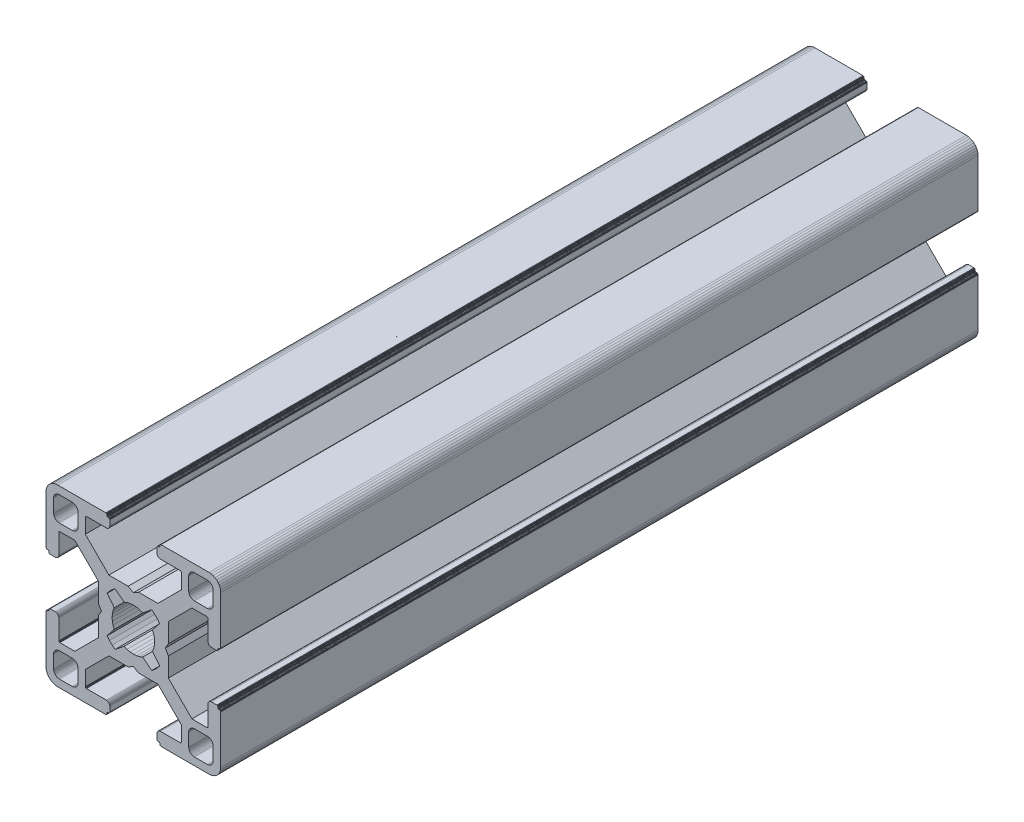
from build123d import *

# Parameters (mm, degrees)
BOSS_EXTRUDE1_DEPTH = 130


with BuildPart() as part:
    # Sketch1 → Boss-Extrude1 (new body)
    with BuildSketch(Plane.XY):
        Polygon((28.34729664, 29.969613999), (28.000000864, 29.999999329), (19.750000909, 29.999999329), (19.715268165, 29.996961355), (19.681595266, 29.987938702), (19.649999216, 29.973205179), (19.621443003, 29.953207821), (19.596790895, 29.928557575), (19.576793537, 29.899999499), (19.562061876, 29.868405312), (19.55303736, 29.834728688), (19.549999386, 29.799999669), (19.549999386, 29.699999839), (19.546961412, 29.665268958), (19.537936896, 29.631596059), (19.523203373, 29.599998146), (19.503207877, 29.571441934), (19.478557631, 29.546789825), (19.449999556, 29.526794329), (19.418403506, 29.512060806), (19.384728745, 29.503038153), (19.349999726, 29.500000179), (19.249999896, 29.500000179), (19.215267517, 29.496958527), (19.181592755, 29.487935874), (19.149996706, 29.47320235), (19.12143863, 29.453206855), (19.096788384, 29.428554746), (19.076791026, 29.399996671), (19.062057503, 29.368402484), (19.05303485, 29.334725859), (19.049996876, 29.299998703), (19.049996876, 28.39999837), (19.059110798, 28.29580945), (19.08618062, 28.194785165), (19.13038119, 28.099997016), (19.190369539, 28.014324653), (19.264324002, 27.94037019), (19.349996366, 27.88038184), (19.444784515, 27.836181271), (19.545806937, 27.809111449), (19.650010894, 27.799984574), (23.050010706, 27.799984574), (23.084741588, 27.7969466), (23.118414487, 27.787923946), (23.150012399, 27.773190423), (23.178568612, 27.753193065), (23.203220721, 27.728542819), (23.223218079, 27.699984744), (23.237949739, 27.668386831), (23.246974255, 27.634713932), (23.25001142, 27.59998608), (23.25001142, 25.049987618), (19.204474482, 20.999982084), (15.900007876, 20.999982084), (15.000008474, 20.48483404), (14.10000814, 20.999982084), (10.795543398, 20.999982084), (7.997342887, 23.801274731), (6.750011387, 25.049984589), (6.750011387, 27.599983051), (6.753049362, 27.634713932), (6.762072946, 27.668386831), (6.776805538, 27.699984744), (6.796801965, 27.728542819), (6.821454073, 27.753193065), (6.850011218, 27.773190423), (6.881607267, 27.787923946), (6.915282029, 27.7969466), (6.950011048, 27.799984574), (10.350011791, 27.799984574), (10.45420071, 27.809098497), (10.555223133, 27.836168318), (10.650011282, 27.880368888), (10.735683645, 27.940357238), (10.809638108, 28.014311701), (10.869626458, 28.099984064), (10.913827027, 28.194772213), (10.940895918, 28.295796498), (10.950010772, 28.399985417), (10.950010772, 29.299985751), (10.946974575, 29.334739239), (10.93795065, 29.368415522), (10.923215933, 29.400009153), (10.903218427, 29.428566473), (10.878566319, 29.45321765), (10.849999264, 29.473204166), (10.818403214, 29.487937689), (10.784728453, 29.496960342), (10.749999434, 29.500000179), (10.649999604, 29.500000179), (10.615270585, 29.503038153), (10.581595823, 29.512060806), (10.549999774, 29.526794329), (10.521441698, 29.546789825), (10.496791452, 29.571441934), (10.476795025, 29.599998146), (10.462061502, 29.631596059), (10.453037918, 29.665268958), (10.449999943, 29.699999839), (10.449999943, 29.799999669), (10.446961969, 29.834728688), (10.437938385, 29.868405312), (10.423205793, 29.899999499), (10.403208435, 29.928557575), (10.378557257, 29.953207821), (10.350000113, 29.973205179), (10.318404064, 29.987938702), (10.284729302, 29.996961355), (10.250000283, 29.999999329), (1.999999397, 29.999999329), (1.652702689, 29.969613999), (1.315958682, 29.879383743), (0.999999233, 29.732050374), (0.714424066, 29.532089829), (0.467910431, 29.285576195), (0.267948955, 28.999999166), (0.120614655, 28.684040532), (0.030384399, 28.34729664), (0, 28.000000864), (0, 19.750000909), (0.003037974, 19.715268165), (0.012061559, 19.681595266), (0.026795082, 19.649999216), (0.046790577, 19.621441141), (0.071442686, 19.596789032), (0.09999983, 19.576793537), (0.13159588, 19.562060013), (0.165270641, 19.55303736), (0.19999966, 19.549999386), (0.299999461, 19.549999386), (0.334728509, 19.546959549), (0.368403242, 19.537936896), (0.399999321, 19.523203373), (0.428556465, 19.503207877), (0.453208573, 19.478555769), (0.473204069, 19.449997693), (0.487937592, 19.418403506), (0.496961176, 19.384728745), (0.499999151, 19.349999726), (0.499999151, 19.249998033), (0.503038056, 19.215269014), (0.512060709, 19.181594253), (0.526794232, 19.150000066), (0.546790194, 19.121441524), (0.571441837, 19.096789882), (0.60000029, 19.076794925), (0.631595686, 19.062061999), (0.665270619, 19.053039982), (0.700000626, 19.050000801), (1.60000096, 19.050000801), (1.704189879, 19.059116587), (1.805213233, 19.086186409), (1.90000045, 19.130385115), (1.985673745, 19.190375328), (2.059627277, 19.264327928), (2.119616325, 19.350002154), (2.163816196, 19.444788441), (2.190886018, 19.545812726), (2.200000872, 19.650001645), (2.200000872, 23.050001457), (2.203039777, 23.084732338), (2.212062431, 23.118405237), (2.226795954, 23.15000315), (2.246792381, 23.178559362), (2.271443558, 23.203211471), (2.300000702, 23.223206967), (2.331596752, 23.23794049), (2.365271513, 23.246965006), (2.400001464, 23.250001117), (4.950000857, 23.250001117), (7.997332093, 20.202670812), (8.995535423, 19.204467788), (8.995535423, 15.900001182), (9.515148227, 15.00000178), (8.995535423, 14.100002378), (8.995535423, 10.795536704), (4.950000857, 6.750002138), (2.400001464, 6.750002138), (2.365271513, 6.753040112), (2.331596752, 6.762063697), (2.300000702, 6.77679722), (2.271443558, 6.796793647), (2.246792381, 6.821444824), (2.226795954, 6.850001968), (2.212062431, 6.881598018), (2.203039777, 6.915272779), (2.200000872, 6.950002729), (2.200000872, 10.350002542), (2.190896812, 10.454174265), (2.16382699, 10.555197618), (2.119627119, 10.649984836), (2.059638071, 10.735658131), (1.985684539, 10.809611663), (1.900011244, 10.869600944), (1.805224027, 10.913800582), (1.704200673, 10.940870404), (1.600011754, 10.949986189), (0.70001142, 10.949986189), (0.665281355, 10.946948596), (0.631606253, 10.937926283), (0.600010578, 10.923193954), (0.571451747, 10.903199537), (0.546799638, 10.87854836), (0.526794232, 10.850000195), (0.512060709, 10.818404146), (0.503038056, 10.784730315), (0.499999151, 10.750000365), (0.499999151, 10.650000535), (0.496961176, 10.615270585), (0.487937592, 10.581596754), (0.473204069, 10.550000705), (0.453208573, 10.521443561), (0.428556465, 10.496791452), (0.399999321, 10.476795956), (0.368403242, 10.462062433), (0.334728509, 10.453038849), (0.299999461, 10.449999943), (0.19999966, 10.449999943), (0.165270641, 10.446961969), (0.13159588, 10.437939316), (0.09999983, 10.423205793), (0.071442686, 10.403209366), (0.046790577, 10.378558189), (0.026795082, 10.350000113), (0.012061559, 10.318404064), (0.003037974, 10.284729302), (0, 10.250000283), (0, 1.999999397), (0.030384399, 1.652702689), (0.120614655, 1.315958682), (0.267948955, 0.999999233), (0.467910431, 0.714424066), (0.714424066, 0.467910431), (0.999999233, 0.267948955), (1.315958682, 0.120614655), (1.652702689, 0.030384399), (1.999999397, 0), (10.250000283, 0), (10.284729302, 0.003037974), (10.318404064, 0.012061559), (10.350000113, 0.026795082), (10.378557257, 0.046790577), (10.403208435, 0.071442686), (10.423205793, 0.09999983), (10.437938385, 0.13159588), (10.446961969, 0.165270641), (10.449999943, 0.19999966), (10.449999943, 0.300000422), (10.453037918, 0.334729441), (10.462061502, 0.368404202), (10.476795025, 0.400000252), (10.496791452, 0.428557396), (10.521441698, 0.453208573), (10.549999774, 0.473205), (10.581595823, 0.487938523), (10.615270585, 0.496961176), (10.649999604, 0.500000082), (10.749999434, 0.500000082), (10.784728453, 0.503038056), (10.818403214, 0.512060709), (10.849999264, 0.526794232), (10.878547894, 0.546800104), (10.903198606, 0.571451747), (10.923194493, 0.6000102), (10.93792742, 0.631606528), (10.946949437, 0.66528146), (10.950010772, 0.699984975), (10.950010772, 1.599985308), (10.940895918, 1.704174228), (10.913827027, 1.805197581), (10.869626458, 1.89998573), (10.809638108, 1.985658094), (10.735683645, 2.059612557), (10.650011282, 2.119600674), (10.555223133, 2.163801476), (10.45420071, 2.190870367), (10.350011791, 2.199985221), (6.950011048, 2.199985221), (6.915282029, 2.203024126), (6.881607267, 2.212046779), (6.850011218, 2.226780302), (6.821454073, 2.246776729), (6.796801965, 2.271427907), (6.776805538, 2.299985982), (6.762072946, 2.331582032), (6.753049362, 2.365256793), (6.750011387, 2.399985812), (6.750011387, 4.949985206), (9.787457566, 7.990785077), (10.795545277, 8.999985833), (14.100010019, 8.999985833), (15.000010353, 9.515133877), (15.900009756, 8.999985833), (19.204476361, 8.999985833), (20.21256413, 7.990786065), (23.25001142, 4.949988235), (23.25001142, 2.399988841), (23.246974255, 2.365256793), (23.237949739, 2.331582032), (23.223218079, 2.299985982), (23.203220721, 2.271427907), (23.178568612, 2.246776729), (23.150012399, 2.226780302), (23.118414487, 2.212046779), (23.084741588, 2.203024126), (23.050010706, 2.199985221), (19.650010894, 2.199985221), (19.545806937, 2.190883319), (19.444784515, 2.163814428), (19.349996366, 2.119613626), (19.264324002, 2.059625509), (19.190369539, 1.985671046), (19.13038119, 1.899998682), (19.08618062, 1.805210533), (19.059110798, 1.70418718), (19.049996876, 1.599998261), (19.049996876, 0.699997927), (19.053035506, 0.665268966), (19.062058795, 0.631594374), (19.076792915, 0.599998603), (19.096790813, 0.571440905), (19.121441524, 0.546790194), (19.149999978, 0.526794306), (19.181596306, 0.51206138), (19.215271238, 0.503039363), (19.249999896, 0.500000082), (19.349999726, 0.500000082), (19.384728745, 0.496961176), (19.418403506, 0.487938523), (19.449999556, 0.473205), (19.478557631, 0.453208573), (19.503207877, 0.428557396), (19.523203373, 0.400000252), (19.537936896, 0.368404202), (19.546961412, 0.334729441), (19.549999386, 0.300000422), (19.549999386, 0.19999966), (19.55303736, 0.165270641), (19.562061876, 0.13159588), (19.576793537, 0.09999983), (19.596789964, 0.071441755), (19.621442072, 0.046789646), (19.649998285, 0.02679415), (19.681594335, 0.012060627), (19.715267234, 0.003037043), (19.750000909, 0), (28.000000864, 0), (28.34729664, 0.030384399), (28.684040532, 0.120614655), (28.999999166, 0.267948955), (29.285576195, 0.467910431), (29.532089829, 0.714424066), (29.732050374, 0.999999233), (29.879383743, 1.315958682), (29.969613999, 1.652702689), (29.999999329, 1.999999397), (29.999999329, 10.250000283), (29.996974806, 10.284715361), (29.987951516, 10.318389952), (29.973217396, 10.349985723), (29.953219499, 10.378543421), (29.928568787, 10.403194133), (29.899999499, 10.423205793), (29.868405312, 10.437939316), (29.834728688, 10.446961969), (29.799999669, 10.449999943), (29.699999839, 10.449999943), (29.664909937, 10.453400043), (29.631233313, 10.462423628), (29.599637263, 10.477157151), (29.57108105, 10.497152646), (29.546427079, 10.521804755), (29.526433446, 10.550361899), (29.511699923, 10.581957949), (29.502675407, 10.615631779), (29.499637433, 10.650361729), (29.499637433, 10.750361559), (29.49697202, 10.784715548), (29.487949367, 10.818389378), (29.473215844, 10.849985428), (29.453220348, 10.878542572), (29.428568239, 10.90319468), (29.400010164, 10.923190176), (29.368415977, 10.937923699), (29.334741215, 10.946947284), (29.300012197, 10.949986189), (28.400011863, 10.949986189), (28.29581215, 10.9408876), (28.194787865, 10.913817778), (28.099999716, 10.86961814), (28.014327352, 10.809628859), (27.940374752, 10.735675327), (27.880384539, 10.650002032), (27.836185833, 10.555214814), (27.809114148, 10.454191461), (27.800000225, 10.350002542), (27.800000225, 6.950002729), (27.796962251, 6.915272779), (27.787939598, 6.881598018), (27.773206075, 6.850001968), (27.753208716, 6.821444824), (27.728558471, 6.796793647), (27.700000395, 6.77679722), (27.668404345, 6.762063697), (27.634729584, 6.753040112), (27.599998702, 6.750002138), (25.05000024, 6.750002138), (23.809199132, 7.99080223), (21.004464477, 10.795534588), (21.004464477, 14.100000262), (20.484851673, 14.999999665), (21.004464477, 15.899999067), (21.004464477, 19.204465672), (25.05000024, 23.250001117), (27.599998702, 23.250001117), (27.634729584, 23.246965006), (27.668404345, 23.23794049), (27.700000395, 23.223206967), (27.728558471, 23.203211471), (27.753208716, 23.178559362), (27.773206075, 23.15000315), (27.787939598, 23.118405237), (27.796962251, 23.084732338), (27.800000225, 23.050001457), (27.800000225, 19.650001645), (27.809114148, 19.545812726), (27.836185833, 19.444788441), (27.880384539, 19.350002154), (27.940370508, 19.264323684), (28.014323108, 19.190371084), (28.099995472, 19.130380872), (28.194783621, 19.086182165), (28.295807906, 19.059112343), (28.400001069, 19.050000801), (29.300001402, 19.050000801), (29.334730421, 19.053040638), (29.368405183, 19.062063291), (29.39999937, 19.076796814), (29.42819671, 19.097149726), (29.452848353, 19.1218023), (29.472843309, 19.150360754), (29.487576235, 19.181955219), (29.496598252, 19.215630151), (29.499637433, 19.250359227), (29.499637433, 19.35036092), (29.502675407, 19.385089939), (29.511699923, 19.4187647), (29.526433446, 19.450358887), (29.546427079, 19.478916963), (29.57108105, 19.503569071), (29.599637263, 19.523564567), (29.631233313, 19.53829809), (29.664909937, 19.547320743), (29.699999839, 19.549999386), (29.799999669, 19.549999386), (29.834728688, 19.55303736), (29.868405312, 19.562060013), (29.899999499, 19.576793537), (29.928557575, 19.596789032), (29.953207821, 19.621441141), (29.973205179, 19.649999216), (29.987938702, 19.681595266), (29.996961355, 19.715268165), (29.999999329, 19.750000909), (29.999999329, 28.000000864), (29.969613999, 28.34729664), (29.879383743, 28.684040532), (29.732050374, 28.999999166), (29.532089829, 29.285576195), (29.285576195, 29.532089829), (28.999999166, 29.732050374), (28.684040532, 29.879383743), align=None)
        Polygon((1.299998723, 25.499999523), (1.299998723, 27.699999511), (1.312309876, 27.856435627), (1.348942518, 28.009016067), (1.408992335, 28.153989464), (1.490981318, 28.287785128), (1.592892222, 28.407108039), (1.71221327, 28.50901708), (1.846008119, 28.591006994), (1.9909814, 28.651056811), (2.143563703, 28.687689453), (2.299998887, 28.699999675), (4.499998875, 28.699999675), (4.656434059, 28.687689453), (4.809016362, 28.651056811), (4.953989759, 28.591006994), (5.087784491, 28.50901708), (5.207106471, 28.407108039), (5.309016444, 28.287785128), (5.391005427, 28.153989464), (5.451056175, 28.009016067), (5.487687886, 27.856435627), (5.499999039, 27.699999511), (5.499999039, 25.499999523), (5.487687886, 25.34356527), (5.451056175, 25.190982968), (5.391005427, 25.04600957), (5.309016444, 24.912213907), (5.207106471, 24.792892858), (5.087784491, 24.690981954), (4.953989759, 24.60899204), (4.809016362, 24.548944086), (4.656434059, 24.512309581), (4.499998875, 24.499999359), (2.299998887, 24.499999359), (2.143563703, 24.512309581), (1.9909814, 24.548944086), (1.846008119, 24.60899204), (1.71221327, 24.690981954), (1.592892222, 24.792892858), (1.490981318, 24.912213907), (1.408992335, 25.04600957), (1.348942518, 25.190982968), (1.312309876, 25.34356527), align=None, mode=Mode.SUBTRACT)
        Polygon((25.34356527, 28.687689453), (25.499999523, 28.699999675), (27.699999511, 28.699999675), (27.856435627, 28.687689453), (28.009017929, 28.651056811), (28.153991327, 28.591006994), (28.28778699, 28.50901708), (28.407108039, 28.407108039), (28.50901708, 28.287785128), (28.591006994, 28.153989464), (28.651056811, 28.009016067), (28.687689453, 27.856435627), (28.700001538, 27.699999511), (28.700001538, 25.499999523), (28.687689453, 25.34356527), (28.651056811, 25.190982968), (28.591006994, 25.04600957), (28.50901708, 24.912213907), (28.407108039, 24.792892858), (28.28778699, 24.690981954), (28.153991327, 24.60899204), (28.009017929, 24.548944086), (27.856435627, 24.512309581), (27.699999511, 24.499999359), (25.499999523, 24.499999359), (25.34356527, 24.512309581), (25.190982968, 24.548944086), (25.04600957, 24.60899204), (24.912215769, 24.690981954), (24.792892858, 24.792892858), (24.690981954, 24.912213907), (24.608993903, 25.04600957), (24.548944086, 25.190982968), (24.512311444, 25.34356527), (24.500001222, 25.499999523), (24.500001222, 27.699999511), (24.512311444, 27.856435627), (24.548944086, 28.009016067), (24.608993903, 28.153989464), (24.690981954, 28.287785128), (24.792892858, 28.407108039), (24.912215769, 28.50901708), (25.04600957, 28.591006994), (25.190982968, 28.651056811), align=None, mode=Mode.SUBTRACT)
        Polygon((14.999999665, 18.649999052), (15.550030395, 18.608318642), (16.087498516, 18.484227359), (16.600128263, 18.280562013), (18.13592948, 19.518401474), (18.644984812, 19.11874488), (19.103571773, 18.662061542), (19.505336881, 18.154669553), (18.280562013, 16.600130126), (18.484227359, 16.087498516), (18.608318642, 15.550030395), (18.649999052, 14.999999665), (18.608318642, 14.449968934), (18.484227359, 13.912500814), (18.280562013, 13.399870135), (19.505336881, 11.845329776), (19.103571773, 11.337937787), (18.644984812, 10.881252587), (18.13592948, 10.481598787), (16.600128263, 11.719437316), (16.087498516, 11.515771039), (15.550030395, 11.391680688), (14.999999665, 11.349999346), (14.449968934, 11.391680688), (13.912500814, 11.515771039), (13.399870135, 11.719437316), (11.864069849, 10.481598787), (11.355013587, 10.881252587), (10.896427557, 11.337937787), (10.494662449, 11.845329776), (11.719438247, 13.399870135), (11.515771039, 13.912500814), (11.391680688, 14.449968934), (11.349999346, 14.999999665), (11.391680688, 15.550030395), (11.515771039, 16.087498516), (11.719438247, 16.600130126), (10.494662449, 18.154669553), (10.896427557, 18.662061542), (11.355013587, 19.11874488), (11.864069849, 19.518401474), (13.399870135, 18.280562013), (13.912500814, 18.484227359), (14.449968934, 18.608318642), align=None, mode=Mode.SUBTRACT)
        Polygon((4.499998875, 1.299999771), (2.299998887, 1.299999771), (2.143563703, 1.312310807), (1.9909814, 1.348942518), (1.846008119, 1.408992335), (1.71221327, 1.490982249), (1.592892222, 1.592892222), (1.490981318, 1.712214202), (1.408992335, 1.846008934), (1.348942518, 1.990982331), (1.312309876, 2.143564634), (1.299998723, 2.299998887), (1.299998723, 4.499999806), (1.312309876, 4.656434059), (1.348942518, 4.809017293), (1.408992335, 4.95399069), (1.490981318, 5.087785423), (1.592892222, 5.207106471), (1.71221327, 5.309017375), (1.846008119, 5.391006358), (1.9909814, 5.451056175), (2.143563703, 5.487688817), (2.299998887, 5.49999997), (4.499998875, 5.49999997), (4.656434059, 5.487688817), (4.809016362, 5.451056175), (4.953989759, 5.391006358), (5.087784491, 5.309017375), (5.207106471, 5.207106471), (5.309016444, 5.087785423), (5.391005427, 4.95399069), (5.451056175, 4.809017293), (5.487687886, 4.656434059), (5.499999039, 4.499999806), (5.499999039, 2.299998887), (5.487687886, 2.143564634), (5.451056175, 1.990982331), (5.391005427, 1.846008934), (5.309016444, 1.712214202), (5.207106471, 1.592892222), (5.087784491, 1.490982249), (4.953989759, 1.408992335), (4.809016362, 1.348942518), (4.656434059, 1.312310807), align=None, mode=Mode.SUBTRACT)
        Polygon((27.699999511, 1.299999771), (25.499999523, 1.299999771), (25.34356527, 1.312310807), (25.190982968, 1.348942518), (25.04600957, 1.408992335), (24.912215769, 1.490982249), (24.792892858, 1.592892222), (24.690981954, 1.712214202), (24.608993903, 1.846008934), (24.548944086, 1.990982331), (24.512311444, 2.143564634), (24.500001222, 2.299998887), (24.500001222, 4.499999806), (24.512311444, 4.656434059), (24.548944086, 4.809017293), (24.608993903, 4.95399069), (24.690981954, 5.087785423), (24.792892858, 5.207106471), (24.912215769, 5.309017375), (25.04600957, 5.391006358), (25.190982968, 5.451056175), (25.34356527, 5.487688817), (25.499999523, 5.49999997), (27.699999511, 5.49999997), (27.856435627, 5.487688817), (28.009017929, 5.451056175), (28.153991327, 5.391006358), (28.28778699, 5.309017375), (28.407108039, 5.207106471), (28.50901708, 5.087785423), (28.591006994, 4.95399069), (28.651056811, 4.809017293), (28.687689453, 4.656434059), (28.700001538, 4.499999806), (28.700001538, 2.299998887), (28.687689453, 2.143564634), (28.651056811, 1.990982331), (28.591006994, 1.846008934), (28.50901708, 1.712214202), (28.407108039, 1.592892222), (28.28778699, 1.490982249), (28.153991327, 1.408992335), (28.009017929, 1.348942518), (27.856435627, 1.312310807), align=None, mode=Mode.SUBTRACT)
    extrude(amount=-BOSS_EXTRUDE1_DEPTH)


solid = part.part
